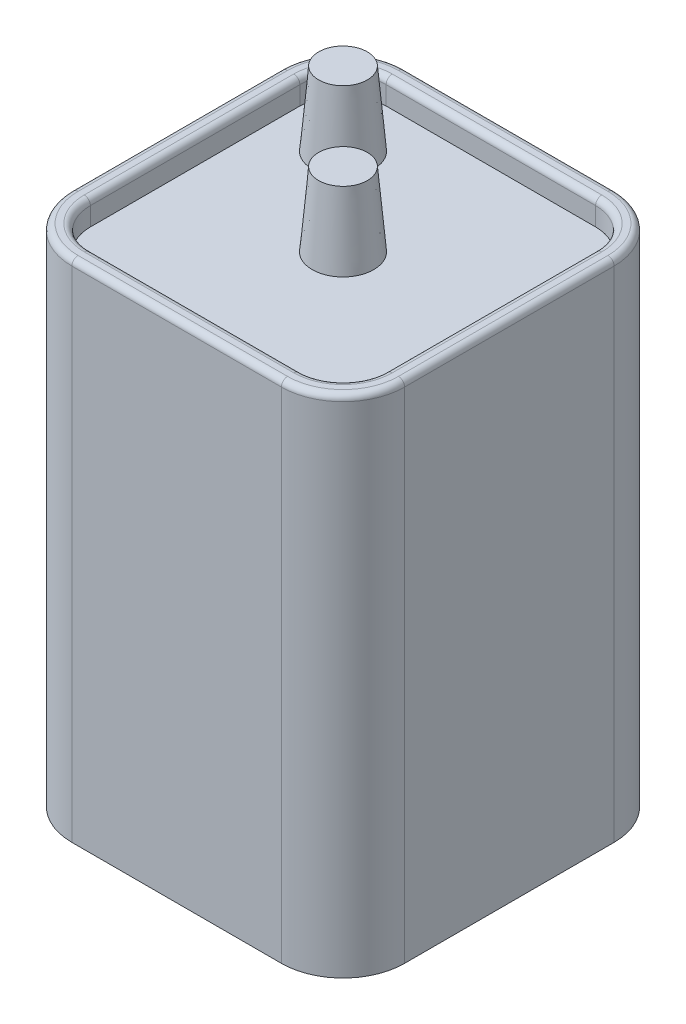
from build123d import *

# Parameters (mm, degrees)
SKETCH2_W          = 68.58
SKETCH2_H          = 68.58
BASE_EXTRUDE_DEPTH = 104.14
SIDE_FILLETS_R     = 12.7
TOP_CUT_DEPTH      = 5.08
TOP_FACE_FILLET_R  = 1.27
SKETCH9_R          = 6.35
TERMINALS_DEPTH    = 15.24
TERMINALS_TAPER    = 5


with BuildPart() as part:
    # Sketch2 → Base-Extrude (new body)
    with BuildSketch(Plane(origin=(0, 0, 0), x_dir=(1, 0, 0), z_dir=(0, 1, 0))):
        Rectangle(SKETCH2_W, SKETCH2_H)
    extrude(amount=BASE_EXTRUDE_DEPTH)

    # Side Fillets
    side_fillets_edges = [part.edges().sort_by_distance(p)[0] for p in [
        (34.29, 52.07, 34.29),
        (-34.29, 52.07, 34.29),
        (-34.29, 52.07, -34.29),
        (34.29, 52.07, -34.29),
    ]]
    fillet(side_fillets_edges, radius=SIDE_FILLETS_R)

    # Sketch5 → Top Cut (cut)
    with BuildSketch(Plane(origin=(0, 104.14, 0), x_dir=(1, 0, 0), z_dir=(0, 1, 0))):
        with BuildLine():
            Line((-30.48, 21.59), (-30.48, -21.59))
            ThreePointArc((-30.48, -21.59), (-27.876179285, -27.876179285), (-21.59, -30.48))
            Line((-21.59, -30.48), (21.59, -30.48))
            ThreePointArc((21.59, -30.48), (27.876179285, -27.876179285), (30.48, -21.59))
            Line((30.48, -21.59), (30.48, 21.59))
            ThreePointArc((30.48, 21.59), (27.876179285, 27.876179285), (21.59, 30.48))
            Line((21.59, 30.48), (-21.59, 30.48))
            ThreePointArc((-21.59, 30.48), (-27.876179285, 27.876179285), (-30.48, 21.59))
        make_face()
    extrude(amount=-TOP_CUT_DEPTH, mode=Mode.SUBTRACT)

    # Top Face Fillet
    top_face_fillet_edges = [part.edges().sort_by_distance(p)[0] for p in [
        (0, 104.14, 34.29),
        (-34.29, 104.14, 0),
        (34.29, 104.14, 0),
        (0, 104.14, -34.29),
        (30.570256121, 104.14, 30.570256121),
        (30.570256121, 104.14, -30.570256121),
        (-30.570256121, 104.14, -30.570256121),
        (-30.570256121, 104.14, 30.570256121),
        (-27.876179285, 104.14, -27.876179285),
        (-30.48, 104.14, 0),
        (-27.876179285, 104.14, 27.876179285),
        (0, 104.14, 30.48),
        (27.876179285, 104.14, 27.876179285),
        (30.48, 104.14, 0),
        (27.876179285, 104.14, -27.876179285),
        (0, 104.14, -30.48),
    ]]
    fillet(top_face_fillet_edges, radius=TOP_FACE_FILLET_R)

    # Sketch9 → Terminals (add)
    with BuildSketch(Plane(origin=(0, 99.06, 0), x_dir=(1, 0, 0), z_dir=(0, 1, 0))):
        Circle(SKETCH9_R)
        with Locations((-17.960512242, 17.960512242)):
            Circle(SKETCH9_R)
    extrude(amount=TERMINALS_DEPTH, taper=TERMINALS_TAPER)


solid = part.part
